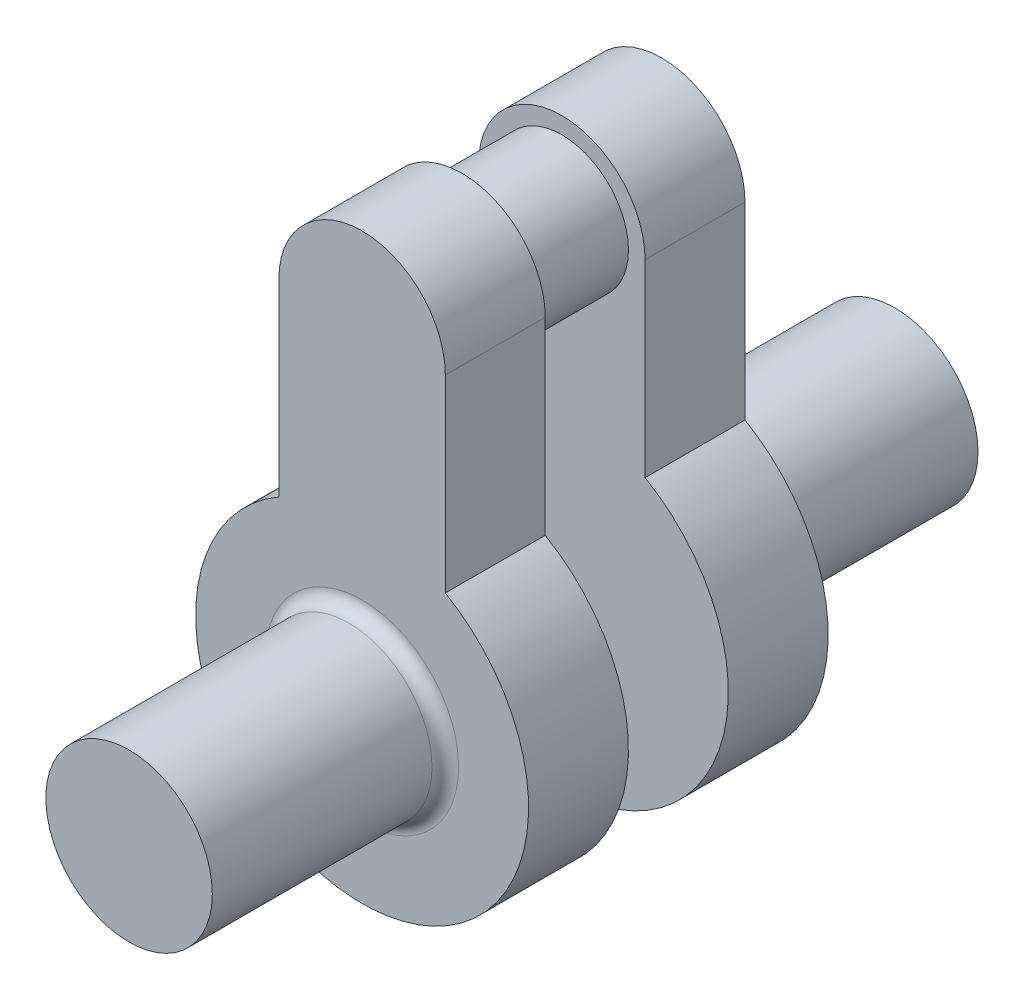
from build123d import *

# Parameters (mm, degrees)
BOSS_EXTRUDE1_DEPTH  = 15
SKETCH2_R            = 12.5
BOSS_EXTRUDE2_DEPTH  = 35
FILLET1_R            = 2
SKETCH3_R            = 10
BOSS_EXTRUDE3_DEPTH  = 15
FILLET1_OF_MIRROR1_R = 2


with BuildPart() as part:
    # Sketch1 → Boss-Extrude1 (new body)
    with BuildSketch(Plane.XY):
        with BuildLine():
            Line((-12.5, 50), (-12.5, 21.650635095))
            ThreePointArc((-12.5, 21.650635095), (0, -25), (12.5, 21.650635095))
            Line((12.5, 21.650635095), (12.5, 50))
            ThreePointArc((12.5, 50), (0, 62.5), (-12.5, 50))
        make_face()
    boss_extrude1 = extrude(amount=BOSS_EXTRUDE1_DEPTH)

    # Sketch2 → Boss-Extrude2 (add)
    with BuildSketch(Plane.XY.offset(15)):
        Circle(SKETCH2_R)
    boss_extrude2 = extrude(amount=BOSS_EXTRUDE2_DEPTH)

    # Fillet1
    fillet1_edges = [part.edges().sort_by_distance(p)[0] for p in [
        (-12.5, 0, 15),
    ]]
    fillet(fillet1_edges, radius=FILLET1_R)

    # Sketch3 → Boss-Extrude3 (add)
    with BuildSketch(Plane(origin=(0, 0, 0), x_dir=(-1, 0, 0), z_dir=(0, 0, -1))):
        with Locations((0, 50)):
            Circle(SKETCH3_R)
    extrude(amount=BOSS_EXTRUDE3_DEPTH)

    # Mirror1: Boss-Extrude1, Boss-Extrude2 across plane
    add(boss_extrude1.mirror(Plane.XY.offset(-7.5)))
    add(boss_extrude2.mirror(Plane.XY.offset(-7.5)))

    # Fillet1 of Mirror1
    fillet1_of_mirror1_edges = [part.edges().sort_by_distance(p)[0] for p in [
        (-12.5, 0, -30),
    ]]
    fillet(fillet1_of_mirror1_edges, radius=FILLET1_OF_MIRROR1_R)


solid = part.part
